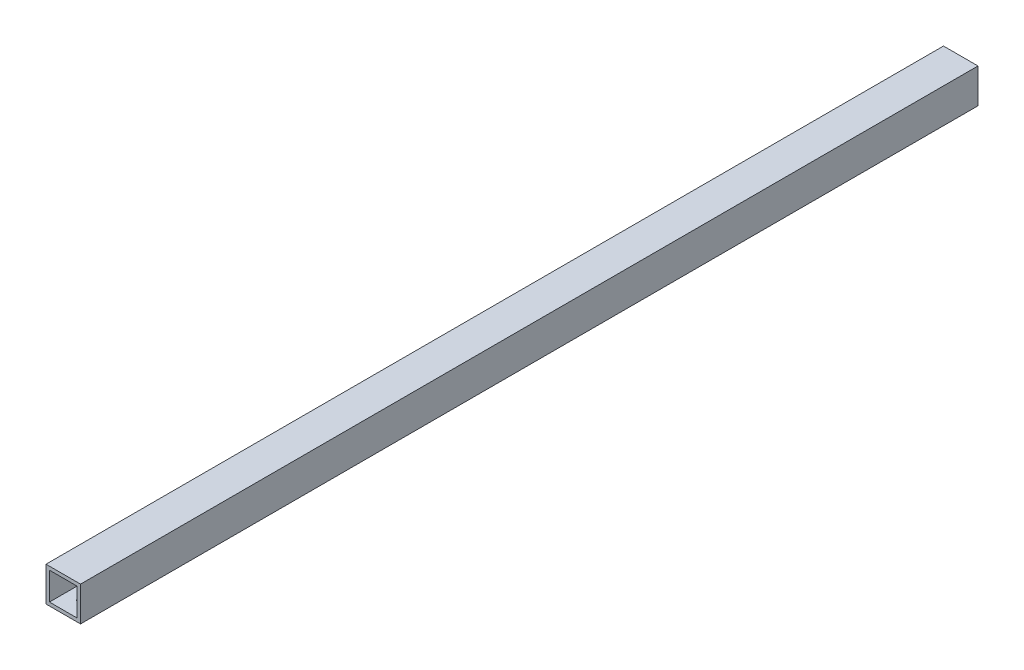
from build123d import *

# Parameters (mm, degrees)
SKETCH_1_W          = 20
SKETCH_1_H          = 20
SKETCH_1_W_2        = 16
SKETCH_1_H_2        = 16
EXTRUDE_1_DEPTH     = 560
SKETCH_4_R          = 2.2
CUT_EXTRUDE_3_DEPTH = 560
SKETCH_5_W          = 20
SKETCH_5_H          = 20
SKETCH_5_W_2        = 16
SKETCH_5_H_2        = 16
EXTRUDE_2_DEPTH     = 20
SKETCH_6_W          = 20
SKETCH_6_H          = 20
SKETCH_6_W_2        = 16
SKETCH_6_H_2        = 16
EXTRUDE_3_DEPTH     = 20
SKETCH_8_R          = 2.2
CUT_EXTRUDE_4_DEPTH = 20
SKETCH_9_R          = 2.2
CUT_EXTRUDE_5_DEPTH = 20
SKETCH_10_W         = 51.42245882
SKETCH_10_H         = 30.440795882
CUT_EXTRUDE_6_DEPTH = 40
SKETCH_11_W         = 39.362638682
SKETCH_11_H         = 52.74733359
CUT_EXTRUDE_7_DEPTH = 40
SKETCH_12_R         = 1
CUT_EXTRUDE_8_DEPTH = 10
SKETCH_13_R         = 1
CUT_EXTRUDE_9_DEPTH = 10
M4X0_7_1_D          = 3.3
M4X0_7_1_DEPTH      = 11.5
M4X0_7_1_TIP        = 0.991420021


with BuildPart() as part:
    # ｽｹｯﾁ1 → ﾎﾞｽ - 押し出し1 (new body)
    with BuildSketch(Plane.XY):
        Rectangle(SKETCH_1_W, SKETCH_1_H)
        Rectangle(SKETCH_1_W_2, SKETCH_1_H_2, mode=Mode.SUBTRACT)
    extrude(amount=EXTRUDE_1_DEPTH)

    # ｽｹｯﾁ4 → ｶｯﾄ - 押し出し3 (cut)
    with BuildSketch(Plane(origin=(0, 10, 0), x_dir=(1, 0, 0), z_dir=(0, 1, 0))):
        with Locations((0, -550)):
            Circle(SKETCH_4_R)
        with Locations((0, -10)):
            Circle(SKETCH_4_R)
    extrude(amount=-CUT_EXTRUDE_3_DEPTH, mode=Mode.SUBTRACT)

    # ｽｹｯﾁ5 → ﾎﾞｽ - 押し出し2 (add)
    with BuildSketch(Plane(origin=(0, 0, 0), x_dir=(-1, 0, 0), z_dir=(0, 0, -1))):
        Rectangle(SKETCH_5_W, SKETCH_5_H)
        Rectangle(SKETCH_5_W_2, SKETCH_5_H_2, mode=Mode.SUBTRACT)
    extrude(amount=EXTRUDE_2_DEPTH)

    # ｽｹｯﾁ6 → ﾎﾞｽ - 押し出し3 (add)
    with BuildSketch(Plane.XY.offset(560)):
        Rectangle(SKETCH_6_W, SKETCH_6_H)
        Rectangle(SKETCH_6_W_2, SKETCH_6_H_2, mode=Mode.SUBTRACT)
    extrude(amount=EXTRUDE_3_DEPTH)

    # ｽｹｯﾁ8 → ｶｯﾄ - 押し出し4 (cut)
    with BuildSketch(Plane(origin=(10, 0, 0), x_dir=(0, 0, -1), z_dir=(1, 0, 0))):
        with Locations((-570, 0)):
            Circle(SKETCH_8_R)
    extrude(amount=-CUT_EXTRUDE_4_DEPTH, mode=Mode.SUBTRACT)

    # ｽｹｯﾁ9 → ｶｯﾄ - 押し出し5 (cut)
    with BuildSketch(Plane(origin=(10, 0, 0), x_dir=(0, 0, -1), z_dir=(1, 0, 0))):
        with Locations((10, 0)):
            Circle(SKETCH_9_R)
    extrude(amount=-CUT_EXTRUDE_5_DEPTH, mode=Mode.SUBTRACT)

    # ｽｹｯﾁ10 → ｶｯﾄ - 押し出し6 (cut)
    with BuildSketch(Plane(origin=(0, 0, -20), x_dir=(-1, 0, 0), z_dir=(0, 0, -1))):
        Rectangle(SKETCH_10_W, SKETCH_10_H)
    extrude(amount=-CUT_EXTRUDE_6_DEPTH, mode=Mode.SUBTRACT)

    # ｽｹｯﾁ11 → ｶｯﾄ - 押し出し7 (cut)
    with BuildSketch(Plane.XY.offset(580)):
        Rectangle(SKETCH_11_W, SKETCH_11_H)
    extrude(amount=-CUT_EXTRUDE_7_DEPTH, mode=Mode.SUBTRACT)

    # ｽｹｯﾁ12 → ｶｯﾄ - 押し出し8 (cut)
    with BuildSketch(Plane(origin=(0, -10, 0), x_dir=(-1, 0, 0), z_dir=(0, -1, 0))):
        with Locations((0, -530)):
            Circle(SKETCH_12_R)
        with Locations((0, -510)):
            Circle(SKETCH_12_R)
    extrude(amount=-CUT_EXTRUDE_8_DEPTH, mode=Mode.SUBTRACT)

    # ｽｹｯﾁ13 → ｶｯﾄ - 押し出し9 (cut)
    with BuildSketch(Plane(origin=(0, -10, 0), x_dir=(-1, 0, 0), z_dir=(0, -1, 0))):
        with Locations((0, -30)):
            Circle(SKETCH_13_R)
        with Locations((0, -50)):
            Circle(SKETCH_13_R)
    extrude(amount=-CUT_EXTRUDE_9_DEPTH, mode=Mode.SUBTRACT)

    # M4x0.7 ねじ穴1
    with Locations(Plane(origin=(0, -10, 30), x_dir=(0, 0, -1), z_dir=(0, -1, 0))):
        with Locations((0, 0), (-20, 0), (-480, 0), (-500, 0)):
            Hole(M4X0_7_1_D / 2, depth=M4X0_7_1_DEPTH)
            with Locations((0, 0, -(M4X0_7_1_DEPTH + M4X0_7_1_TIP / 2))):  # 118° drill point
                Cone(0, M4X0_7_1_D / 2, M4X0_7_1_TIP, mode=Mode.SUBTRACT)


solid = part.part
